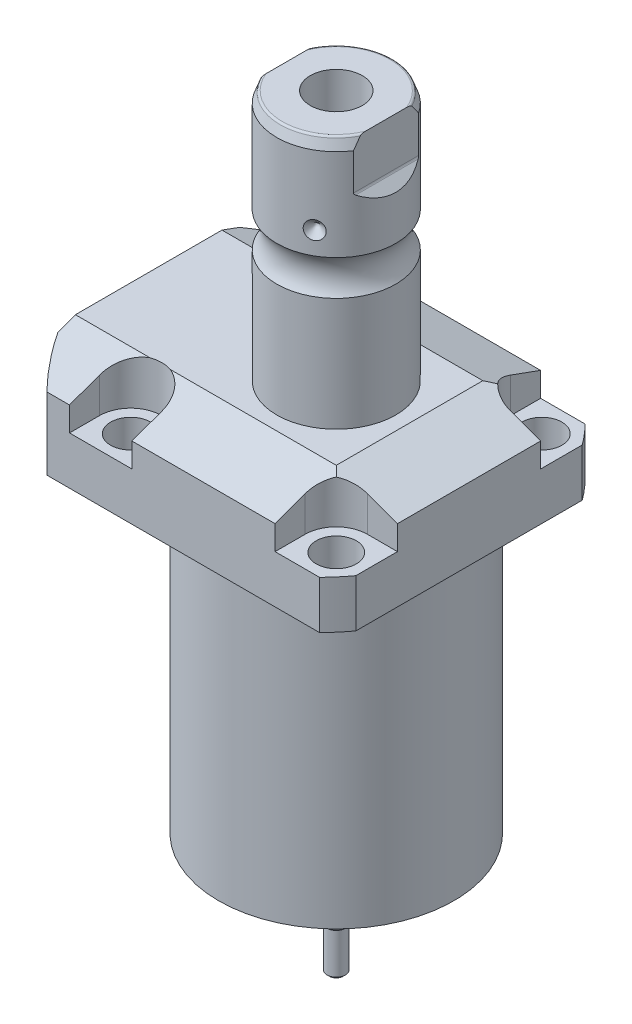
from build123d import *

# Parameters (mm, degrees)
SKETCH1_W                = 70.866
SKETCH1_H                = 85.496
EXTRUDE1_DEPTH           = 104.521
SKETCH2_OUTSIDE_W        = 117.996
SKETCH2_OUTSIDE_H        = 103.366
SKETCH2_OUTSIDE_R        = 50.8
CUT_EXTRUDE1_DEPTH       = 105.521
SKETCH3_W                = 45.1992
SKETCH3_H                = 79.502
FILLET1_R                = 0.381
CUT_EXTRUDE2_DEPTH       = 12.243
CUT_EXTRUDE9_START       = -51.063
CUT_EXTRUDE9_DEPTH       = 87.496
CUT_EXTRUDE7_DEPTH       = 36.433
CUT_EXTRUDE7_DEPTH_BACK  = 36.433
SKETCH10_R               = 1.1811
SKETCH17_W               = 5.3594
SKETCH17_H               = 12.776
HOLE1_AT_2_COUNT         = 2
HOLE1_AT_2_PITCH         = 54.864
HOLE1_AT_3_COUNT         = 2
HOLE1_AT_3_PITCH         = 77.589412886
HOLE1_AT_4_COUNT         = 2
HOLE1_AT_4_PITCH         = 54.864
CHAMFER1_SIZE            = 0.635
FILLET2_R                = 0.635
CIRPATTERN1_COUNT        = 3
CUT_EXTRUDE10_DEPTH      = 36.433
CUT_EXTRUDE10_DEPTH_BACK = 36.433
CUT_EXTRUDE11_DEPTH      = 3.81000762
SKETCH34_W               = 2.70510541
SKETCH34_H               = 1.320802642
SKETCH35_R               = 1.27000254
CUT_EXTRUDE12_DEPTH      = 7.62001524


with BuildPart() as part:
    # Sketch1 → Extrude1 (new body)
    with BuildSketch(Plane(origin=(0, 0, 0), x_dir=(0, 0, 1), z_dir=(0, -1, 0))):
        with Locations((0, 7.315)):
            Rectangle(SKETCH1_W, SKETCH1_H)
    extrude(amount=-EXTRUDE1_DEPTH)

    # Sketch2 outside → Cut-Extrude1 (cut, through all)
    with BuildSketch(Plane.XZ):
        with Locations((-7.315, 0)):
            Rectangle(SKETCH2_OUTSIDE_W, SKETCH2_OUTSIDE_H)
        with Locations((-5.4102, 0)):
            Circle(SKETCH2_OUTSIDE_R, mode=Mode.SUBTRACT)
    extrude(amount=-CUT_EXTRUDE1_DEPTH, mode=Mode.SUBTRACT)

    # Sketch3 → Cut-Revolve1 (revolve, cut)
    with BuildSketch(Plane(origin=(0, 0, 0), x_dir=(0, 0, -1), z_dir=(1, 0, 0))):
        with Locations((53.9941, 39.751)):
            Rectangle(SKETCH3_W, SKETCH3_H)
    revolve(axis=Axis((0, -93.345, 0), (0, 1, 0)), mode=Mode.SUBTRACT)

    # Fillet1
    fillet1_edges = [part.edges().sort_by_distance(p)[0] for p in [
        (0, 79.502, 31.3945),
    ]]
    fillet(fillet1_edges, radius=FILLET1_R)

    # Sketch4 → Cut-Extrude2 (cut)
    with BuildSketch(Plane(origin=(0, 104.521, 0), x_dir=(-1, 0, 0), z_dir=(0, 1, 0))):
        with BuildLine():
            Line((-19.1008, -35.433), (-19.1008, -27.432))
            ThreePointArc((-19.1008, -27.432), (-21.540951985, -21.540951985), (-27.432, -19.1008))
            Line((-27.432, -19.1008), (-35.433, -19.1008))
            Line((-35.433, -19.1008), (-35.433, -35.433))
            Line((-35.433, -35.433), (-19.1008, -35.433))
        make_face()
        with BuildLine():
            Line((35.7632, -35.433), (19.1008, -35.433))
            Line((19.1008, -35.433), (19.1008, -27.432))
            ThreePointArc((19.1008, -27.432), (27.432, -19.1008), (35.7632, -27.432))
            Line((35.7632, -27.432), (35.7632, -35.433))
        make_face()
        with BuildLine():
            Line((19.1008, 35.433), (19.1008, 27.432))
            ThreePointArc((19.1008, 27.432), (27.432, 19.1008), (35.7632, 27.432))
            Line((35.7632, 27.432), (35.7632, 35.433))
            Line((35.7632, 35.433), (19.1008, 35.433))
        make_face()
        with BuildLine():
            Line((-27.432, 19.1008), (-35.433, 19.1008))
            Line((-35.433, 19.1008), (-35.433, 35.433))
            Line((-35.433, 35.433), (-19.1008, 35.433))
            Line((-19.1008, 35.433), (-19.1008, 27.432))
            ThreePointArc((-19.1008, 27.432), (-21.540951985, 21.540951985), (-27.432, 19.1008))
        make_face()
    extrude(amount=-CUT_EXTRUDE2_DEPTH, mode=Mode.SUBTRACT)

    # Sketch5 → Cut-Extrude9 (cut)
    with BuildSketch(Plane(origin=(0, 0, 0), x_dir=(0, 0, -1), z_dir=(1, 0, 0)).offset(CUT_EXTRUDE9_START)):
        Polygon((-19.558, 104.521), (-35.433, 98.742972531), (-35.433, 104.521), align=None)
    cut_extrude9 = extrude(amount=CUT_EXTRUDE9_DEPTH, mode=Mode.SUBTRACT)

    # Mirror1: Cut-Extrude9 across plane
    add(cut_extrude9.mirror(Plane.XY), mode=Mode.SUBTRACT)

    # Sketch9 → Cut-Extrude7 (cut, two sides)
    with BuildSketch(Plane.XY) as cut_extrude7_sk:
        Polygon((19.558, 104.521), (35.433, 98.742972531), (35.433, 104.521), align=None)
    extrude(amount=CUT_EXTRUDE7_DEPTH, mode=Mode.SUBTRACT)
    extrude(cut_extrude7_sk.sketch, amount=-CUT_EXTRUDE7_DEPTH_BACK, mode=Mode.SUBTRACT)

    # Sketch20 → Cut-Revolve4 (revolve, cut)
    with BuildSketch(Plane(origin=(-35.0774, 88.9, -18.1102), x_dir=(0, 1, 0), z_dir=(1, 0, 0)), mode=Mode.PRIVATE) as cut_revolve4_sk:
        Polygon((-9.398, 38.3413), (-7.9502, 38.3413), (-7.9502, 35.8902), (-6.9342, 35.8902), (-6.9342, 33.8836), (4.0386, 33.8836), (4.0386, 32.639), (-9.398, 32.639), align=None)
    cut_revolve4 = revolve(cut_revolve4_sk.sketch.rotate(Axis((-35.0774, 81.620304954, 14.5288), (0, 1, 0)), 180), axis=Axis((-35.0774, 81.620304954, 14.5288), (0, 1, 0)), mode=Mode.SUBTRACT)  # turned: the seam where the file's is

    # Mirror10: Cut-Revolve4 across plane
    add(cut_revolve4.mirror(Plane.XY), mode=Mode.SUBTRACT)

    # Sketch15 → Revolve3 (revolve)
    with BuildSketch(Plane(origin=(0, 0, 0), x_dir=(0, 0, -1), z_dir=(1, 0, 0)), mode=Mode.PRIVATE) as revolve3_sk:
        with BuildLine():
            Line((0, 104.521), (15.875, 104.521))
            Line((15.875, 104.521), (15.875, 134.76390643))
            ThreePointArc((15.875, 134.76390643), (14.3256, 139.471), (15.875, 144.17809357))
            Line((15.875, 144.17809357), (15.875, 168.65599416))
            Line((15.875, 168.65599416), (14.81184082, 171.577))
            Line((14.81184082, 171.577), (0, 171.577))
            Line((0, 171.577), (0, 104.521))
        make_face()
    revolve(revolve3_sk.sketch.rotate(Axis((0, 250.290824608, 0), (0, -1, 0)), 180), axis=Axis((0, 250.290824608, 0), (0, -1, 0)))  # turned: the seam where the file's is

    # Sketch17 → Hole1 (revolve, cut)
    with BuildSketch(Plane(origin=(27.432, 92.278, -27.432), x_dir=(0, 0, 1), z_dir=(1, 0, 0))):
        with Locations((2.6797, 6.388)):
            Rectangle(SKETCH17_W, SKETCH17_H)
    hole1 = revolve(axis=Axis((27.432, -17.722, -27.432), (0, 1, 0)), mode=Mode.SUBTRACT)

    # Hole1 at 2: Hole1 ×2
    with Locations(*[(0, 0, i * HOLE1_AT_2_PITCH) for i in range(1, HOLE1_AT_2_COUNT)]):
        add(hole1, mode=Mode.SUBTRACT)

    # Hole1 at 3: Hole1 ×2
    with Locations(*[Vector(-0.707106781, 0, 0.707106781) * (i * HOLE1_AT_3_PITCH) for i in range(1, HOLE1_AT_3_COUNT)]):
        add(hole1, mode=Mode.SUBTRACT)

    # Hole1 at 4: Hole1 ×2
    with Locations(*[(-i * HOLE1_AT_4_PITCH, 0, 0) for i in range(1, HOLE1_AT_4_COUNT)]):
        add(hole1, mode=Mode.SUBTRACT)

    # Chamfer1
    chamfer1_edges = [part.edges().sort_by_distance(p)[0] for p in [
        (-35.0774, 81.9658, 15.7734),
        (-35.0774, 81.9658, -15.7734),
    ]]
    chamfer(chamfer1_edges, length=CHAMFER1_SIZE)

    # Sketch21 → Cut-Revolve5 (revolve, cut)
    with BuildSketch(Plane.XZ.offset(-92.5068)):
        Polygon((-50.063, -1.9304), (-49.809, -1.9304), (-49.809, -6.3246), (-49.0978, -7.0358), (-35.6358, -7.0358), (-35.6358, -12.9794), (-50.063, -12.9794), align=None)
    cut_revolve5 = revolve(axis=Axis((-57.549532301, 92.5068, -12.9794), (1, 0, 0)), mode=Mode.SUBTRACT)

    # Mirror13: Cut-Revolve5 across plane
    add(cut_revolve5.mirror(Plane.XY), mode=Mode.SUBTRACT)

    # Fillet2
    fillet2_edges = [part.edges().sort_by_distance(p)[0] for p in [
        (0, 171.577, -14.81184082),
    ]]
    fillet(fillet2_edges, radius=FILLET2_R)

    # Sketch26 → Cut-Revolve7 (revolve, cut)
    with BuildSketch(Plane.XY, mode=Mode.PRIVATE) as cut_revolve7_sk:
        Polygon((-15.875, 152.572), (-13.462, 150.159), (-15.875, 150.159), align=None)
    cut_revolve7 = revolve(cut_revolve7_sk.sketch.rotate(Axis((-39.772000707, 150.159, 0), (1, 0, 0)), 90), axis=Axis((-39.772000707, 150.159, 0), (1, 0, 0)), mode=Mode.SUBTRACT)  # turned: the seam where the file's is

    # CirPattern1: Cut-Revolve7 ×3 about axis
    cirpattern1_axis = Axis((0, 250.290824608, 0), (0, 1, 0))
    for i in range(1, CIRPATTERN1_COUNT):
        add(cut_revolve7.rotate(cirpattern1_axis, i * 360 / CIRPATTERN1_COUNT), mode=Mode.SUBTRACT)

    # Sketch27 → Hole2 (revolve, cut)
    with BuildSketch(Plane(origin=(0, 171.577, 0), x_dir=(0, 0, 1), z_dir=(1, 0, 0))):
        Polygon((0, 0), (0, 29.566487704), (6.9342, 25.4), (6.9342, 0), align=None)
    revolve(axis=Axis((0, 175.821199587, 0), (0, -1, 0)), mode=Mode.SUBTRACT)

    # Sketch29 → Cut-Extrude10 (cut, two sides)
    with BuildSketch(Plane.XY) as cut_extrude10_sk:
        with BuildLine():
            Line((13.284, 171.577), (13.284, 158.877))
            ThreePointArc((13.284, 158.877), (13.342003912, 158.585394643), (13.507185078, 158.338183558))
            Line((13.507185078, 158.338183558), (15.875, 155.970368636))
            Line((15.875, 155.970368636), (15.875, 171.577))
            Line((15.875, 171.577), (13.284, 171.577))
        make_face()
        with BuildLine():
            Line((-15.875, 171.577), (-13.284, 171.577))
            Line((-13.284, 171.577), (-13.284, 158.877))
            ThreePointArc((-13.284, 158.877), (-13.342003912, 158.585394643), (-13.507185078, 158.338183558))
            Line((-13.507185078, 158.338183558), (-15.875, 155.970368636))
            Line((-15.875, 155.970368636), (-15.875, 171.577))
        make_face()
    extrude(amount=CUT_EXTRUDE10_DEPTH, mode=Mode.SUBTRACT)
    extrude(cut_extrude10_sk.sketch, amount=-CUT_EXTRUDE10_DEPTH_BACK, mode=Mode.SUBTRACT)

    # Sketch30 → Revolve5 (revolve)
    with BuildSketch(Plane(origin=(0, 0, 0), x_dir=(0, 0, -1), z_dir=(1, 0, 0)), mode=Mode.PRIVATE) as revolve5_sk:
        Polygon((0, 0), (3.17500635, 0), (3.17500635, -19.552553634), (2.438404877, -20.828384811), (2.438404877, -31.623406401), (1.803403607, -32.258407671), (0, -32.258407671), align=None)
    revolve(revolve5_sk.sketch.rotate(Axis((0, -1000, 0), (0, 1, 0)), 180), axis=Axis((0, -1000, 0), (0, 1, 0)))  # turned: the seam where the file's is

    # Sketch33 → Cut-Extrude11 (cut, symmetric)
    with BuildSketch(Plane(origin=(0, 0, 0), x_dir=(0, 0, -1), z_dir=(1, 0, 0))):
        Polygon((2.501905004, -32.258407671), (2.501905004, -16.383375921), (3.17500635, -15.710274575), (3.17500635, -32.258407671), align=None)
        Polygon((-3.17500635, -32.258407671), (-2.501905004, -32.258407671), (-2.501905004, -16.383375921), (-3.17500635, -15.710274575), align=None)
    extrude(amount=CUT_EXTRUDE11_DEPTH, both=True, mode=Mode.SUBTRACT)

    # Sketch34 → Cut-Revolve8 (revolve, cut)
    with BuildSketch(Plane(origin=(0, 0, 0), x_dir=(0, 0, -1), z_dir=(1, 0, 0)), mode=Mode.PRIVATE) as cut_revolve8_sk:
        with Locations((12.998475997, 0.660401321)):
            Rectangle(SKETCH34_W, SKETCH34_H)
    revolve(cut_revolve8_sk.sketch.rotate(Axis((0, -1000, 0), (0, 1, 0)), 218.00100076), axis=Axis((0, -1000, 0), (0, 1, 0)), mode=Mode.SUBTRACT)  # turned: the seam where the file's is

    # Sketch35 → Cut-Extrude12 (cut)
    with BuildSketch(Plane.XZ):
        with Locations(Location((19.431038862, 0, 0), (0, 0, 270))):  # turned: the seam where the file's is
            Circle(SKETCH35_R)
        with Locations(Location((18.768942269, -5.029122924, 0), (0, 0, 270))):  # turned: the seam where the file's is
            Circle(SKETCH35_R)
        with Locations(Location((-13.739819345, 13.739819345, 0), (0, 0, 90))):  # turned: the seam where the file's is
            Circle(SKETCH35_R)
        with Locations(Location((-9.715519431, 16.827773276, 0), (0, 0, 90))):  # turned: the seam where the file's is
            Circle(SKETCH35_R)
        with Locations(Location((-13.739819345, -13.739819345, 0), (0, 0, 270))):  # turned: the seam where the file's is
            Circle(SKETCH35_R)
        with Locations(Location((-9.715519431, -16.827773276, 0), (0, 0, 270))):  # turned: the seam where the file's is
            Circle(SKETCH35_R)
    extrude(amount=-CUT_EXTRUDE12_DEPTH, mode=Mode.SUBTRACT)


with BuildPart() as body_2:
    # Sketch10 → Revolve4 (revolve)
    with BuildSketch(Plane(origin=(-35.0774, 88.9, -18.1102), x_dir=(0, 1, 0), z_dir=(1, 0, 0))):
        with Locations((-9.1313, 8.1026)):
            Circle(SKETCH10_R)
    revolve(axis=Axis((-35.0774, 87.86749, -14.5288), (0, 1, 0)))


with BuildPart() as body_3:
    # Mirror12: mirrored copy
    add(body_2.part.mirror(Plane.XY))


solid = Compound([part.part, body_2.part, body_3.part])
